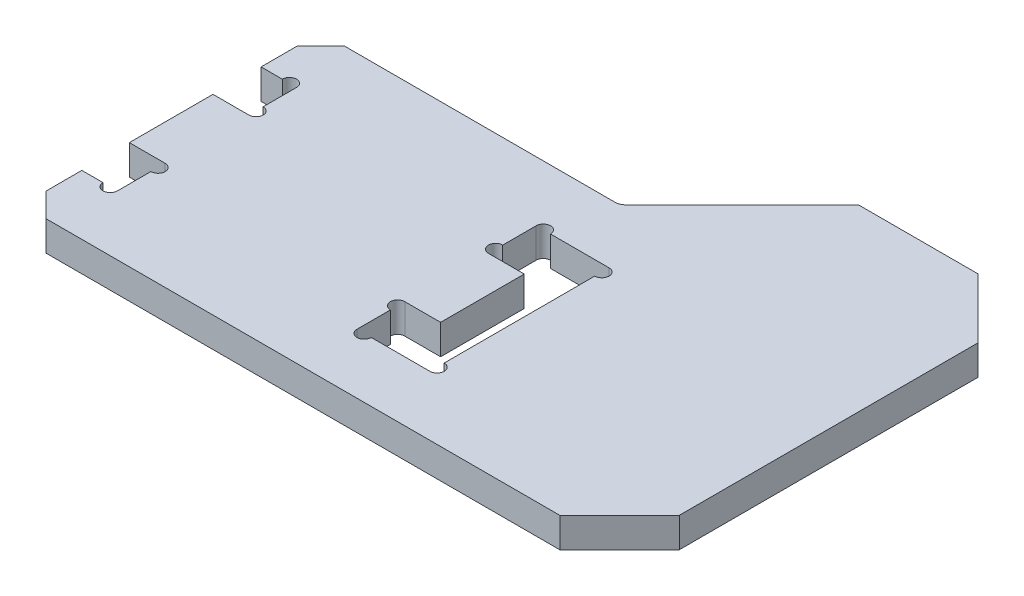
from build123d import *

# Parameters (mm, degrees)
EXTRUDE_1_DEPTH     = 1.25
SKETCH_2_R          = 0.6
CUT_EXTRUDE_1_DEPTH = 3.5
CHAMFER_2_SIZE      = 2
FILLET_1_R          = 1
CHAMFER_3_SIZE      = 5


with BuildPart() as part:
    # 草图1 → 凸台-拉伸1 (new body, symmetric)
    with BuildSketch(Plane(origin=(0, 0, 0), x_dir=(1, 0, 0), z_dir=(0, 1, 0))):
        Polygon((-25, 12.5), (0, 12.5), (10, 22.5), (25, 22.5), (25, -12.5), (-25, -12.5), (-25, -7.5), (-22.025, -7.5), (-22.025, -3.5), (-25.025, -3.5), (-25.025, 3.5), (-22.025, 3.5), (-22.025, 7.5), (-25, 7.5), align=None)
        Polygon((-1.975, -3.5), (-1.975, -7.5), (4.125, -7.5), (4.125, 7.5), (-1.975, 7.5), (-1.975, 3.5), (1.025, 3.5), (1.025, -3.5), align=None, mode=Mode.SUBTRACT)
    extrude(amount=EXTRUDE_1_DEPTH, both=True)

    # 草图2 → 切除-拉伸1 (cut, through all)
    with BuildSketch(Plane(origin=(0, 1.25, 0), x_dir=(1, 0, 0), z_dir=(0, 1, 0))):
        with Locations((-22.025, 4.1)):
            Circle(SKETCH_2_R)
        with Locations((-22.625, 7.5)):
            Circle(SKETCH_2_R)
        with Locations((-22.625, -7.5)):
            Circle(SKETCH_2_R)
        with Locations((-22.025, -4.1)):
            Circle(SKETCH_2_R)
        with Locations((-1.975, 4.1)):
            Circle(SKETCH_2_R)
        with Locations((-1.375, 7.5)):
            Circle(SKETCH_2_R)
        with Locations((-1.375, -7.5)):
            Circle(SKETCH_2_R)
        with Locations((-1.975, -4.1)):
            Circle(SKETCH_2_R)
        with Locations((4.125, -6.9)):
            Circle(SKETCH_2_R)
        with Locations((4.125, 6.9)):
            Circle(SKETCH_2_R)
    extrude(amount=-CUT_EXTRUDE_1_DEPTH, mode=Mode.SUBTRACT)

    # 倒角2
    chamfer_2_edges = [part.edges().sort_by_distance(p)[0] for p in [
        (-25, 0, -12.5),
        (-25, 0, 12.5),
    ]]
    chamfer(chamfer_2_edges, length=CHAMFER_2_SIZE)

    # 圆角1
    fillet_1_edges = [part.edges().sort_by_distance(p)[0] for p in [
        (0, 0, -12.5),
    ]]
    fillet(fillet_1_edges, radius=FILLET_1_R)

    # 倒角3
    chamfer_3_edges = [part.edges().sort_by_distance(p)[0] for p in [
        (25, 0, -22.5),
        (25, 0, 12.5),
    ]]
    chamfer(chamfer_3_edges, length=CHAMFER_3_SIZE)


solid = part.part
